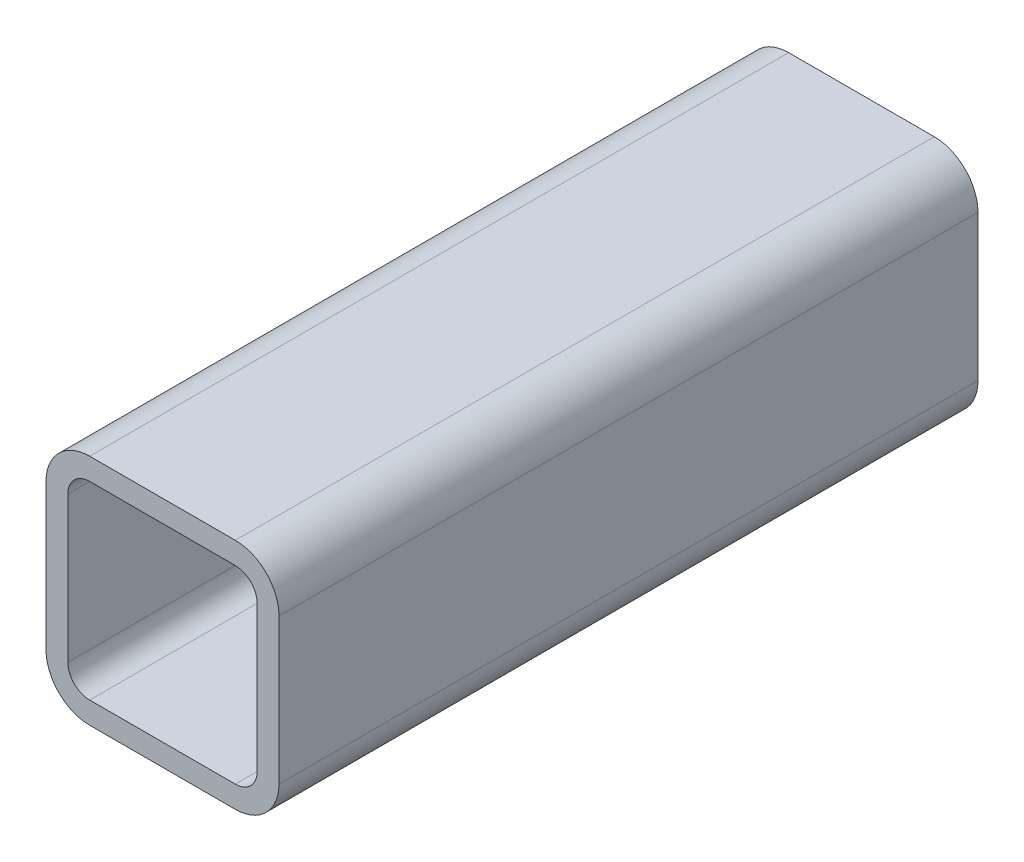
from build123d import *

# Parameters (mm, degrees)
BASETUBES_DEPTH = 76.2


with BuildPart() as part:
    # Sketch1 → BaseTubeS (new body, symmetric)
    with BuildSketch(Plane.XY):
        with BuildLine():
            Line((9.52499175, 0), (41.27496425, 0))
            ThreePointArc((41.27496425, 0), (48.010150507, 2.789805493), (50.799956, 9.52499175))
            Line((50.799956, 9.52499175), (50.799956, 41.27496425))
            ThreePointArc((50.799956, 41.27496425), (48.010150507, 48.010150507), (41.27496425, 50.799956))
            Line((41.27496425, 50.799956), (9.52499175, 50.799956))
            ThreePointArc((9.52499175, 50.799956), (2.789805493, 48.010150507), (0, 41.27496425))
            Line((0, 41.27496425), (0, 9.52499175))
            ThreePointArc((0, 9.52499175), (2.789805493, 2.789805493), (9.52499175, 0))
        make_face()
        with BuildLine():
            Line((9.52499175, 4.762495875), (41.27496425, 4.762495875))
            ThreePointArc((41.27496425, 4.762495875), (44.642557379, 6.157398621), (46.037460125, 9.52499175))
            Line((46.037460125, 9.52499175), (46.037460125, 41.27496425))
            ThreePointArc((46.037460125, 41.27496425), (44.642557379, 44.642557379), (41.27496425, 46.037460125))
            Line((41.27496425, 46.037460125), (9.52499175, 46.037460125))
            ThreePointArc((9.52499175, 46.037460125), (6.157398621, 44.642557379), (4.762495875, 41.27496425))
            Line((4.762495875, 41.27496425), (4.762495875, 9.52499175))
            ThreePointArc((4.762495875, 9.52499175), (6.157398621, 6.157398621), (9.52499175, 4.762495875))
        make_face(mode=Mode.SUBTRACT)
    extrude(amount=BASETUBES_DEPTH, both=True)


solid = part.part
